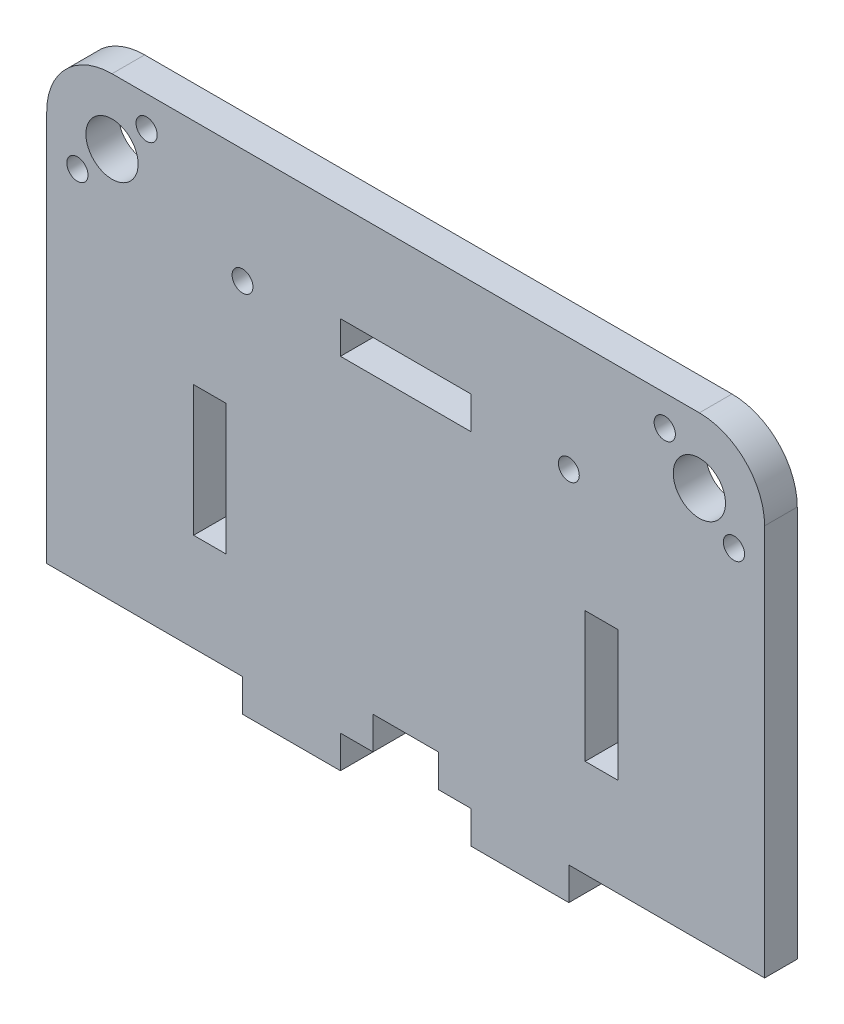
from build123d import *

# Parameters (mm, degrees)
ESQUISSE1_R             = 1.6
ESQUISSE1_W             = 5
ESQUISSE1_H             = 20
ESQUISSE1_W_2           = 20
ESQUISSE1_H_2           = 5
BOSS_EXTRU_1_DEPTH      = 5
CONG_1_R                = 10
ESQUISSE2_R             = 4
ESQUISSE2_R_2           = 1.625
ENL_V_MAT_EXTRU_1_DEPTH = 10


with BuildPart() as part:
    # Esquisse1 → Boss.-Extru.1 (new body)
    with BuildSketch(Plane.XY):
        Polygon((-55, 35), (55, 35), (55, -35), (25, -35), (25, -40), (10, -40), (10, -35), (5, -35), (5, -30), (-5, -30), (-5, -35), (-10, -35), (-10, -40), (-25, -40), (-25, -35), (-55, -35), align=None)
        with Locations((-25, 17.5)):
            Circle(ESQUISSE1_R, mode=Mode.SUBTRACT)
        with Locations((25, 17.5)):
            Circle(ESQUISSE1_R, mode=Mode.SUBTRACT)
        with Locations((-30, -10)):
            Rectangle(ESQUISSE1_W, ESQUISSE1_H, mode=Mode.SUBTRACT)
        with Locations((30, -10)):
            Rectangle(ESQUISSE1_W, ESQUISSE1_H, mode=Mode.SUBTRACT)
        with Locations((0, 17.5)):
            Rectangle(ESQUISSE1_W_2, ESQUISSE1_H_2, mode=Mode.SUBTRACT)
    extrude(amount=BOSS_EXTRU_1_DEPTH)

    # Congé1
    cong_1_edges = [part.edges().sort_by_distance(p)[0] for p in [
        (-55, 35, 2.5),
        (55, 35, 2.5),
    ]]
    fillet(cong_1_edges, radius=CONG_1_R)

    # Esquisse2 → Enlèv. mat.-Extru.1 (cut)
    with BuildSketch(Plane(origin=(0, 0, 0), x_dir=(-1, 0, 0), z_dir=(0, 0, -1))):
        with Locations((-45, 25)):
            Circle(ESQUISSE2_R)
        with Locations((-50.303300859, 19.696699141)):
            Circle(ESQUISSE2_R_2)
        with Locations((-39.696699141, 30.303300859)):
            Circle(ESQUISSE2_R_2)
    enl_v_mat_extru_1 = extrude(amount=-ENL_V_MAT_EXTRU_1_DEPTH, mode=Mode.SUBTRACT)

    # Symétrie1: Enlèv. mat.-Extru.1 across plane
    add(enl_v_mat_extru_1.mirror(Plane(origin=(0, 0, 0), x_dir=(0, 0, 1), z_dir=(1, 0, 0))), mode=Mode.SUBTRACT)


solid = part.part
